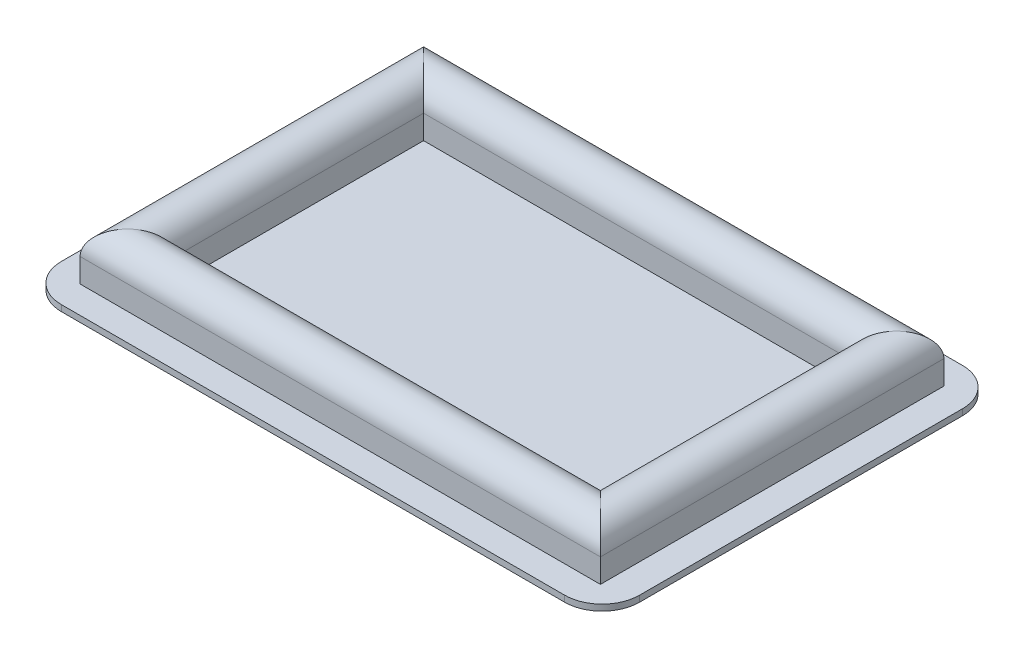
from build123d import *

# Parameters (mm, degrees)
BOSS_EXTRUDE1_DEPTH = 0.9


with BuildPart() as part:
    # Sketch1 → Boss-Extrude1 (new body)
    with BuildSketch(Plane(origin=(0, 0, 0), x_dir=(1, 0, 0), z_dir=(0, 1, 0))):
        with BuildLine():
            Line((37, -29.25), (-37, -29.25))
            ThreePointArc((-37, -29.25), (-40.889087297, -27.639087297), (-42.5, -23.75))
            Line((-42.5, -23.75), (-42.5, 23.75))
            ThreePointArc((-42.5, 23.75), (-40.889087297, 27.639087297), (-37, 29.25))
            Line((-37, 29.25), (37, 29.25))
            ThreePointArc((37, 29.25), (40.889087297, 27.639087297), (42.5, 23.75))
            Line((42.5, 23.75), (42.5, -23.75))
            ThreePointArc((42.5, -23.75), (40.889087297, -27.639087297), (37, -29.25))
        make_face()
    extrude(amount=BOSS_EXTRUDE1_DEPTH)

    # Sweep1: sweep along a path in Sketch2
    with BuildLine(Plane(origin=(0, 0.9, 0), x_dir=(1, 0, 0), z_dir=(0, 1, 0))) as sweep1_path:
        Line((34.75, -21.75), (-34.75, -21.75))
        Line((-34.75, -21.75), (-34.75, 21.75))
        Line((-34.75, 21.75), (34.75, 21.75))
        Line((34.75, 21.75), (34.75, -21.75))
    # Sketch3 → Sweep1 (sweep)
    with BuildSketch(Plane.XY):
        with BuildLine():
            Line((-38.25, 0.9), (-31.25, 0.9))
            Line((-31.25, 0.9), (-31.25, 4.4))
            ThreePointArc((-31.25, 4.4), (-34.75, 7.9), (-38.25, 4.4))
            Line((-38.25, 4.4), (-38.25, 0.9))
        make_face()
    sweep(path=sweep1_path.line, transition=Transition.RIGHT)


solid = part.part
